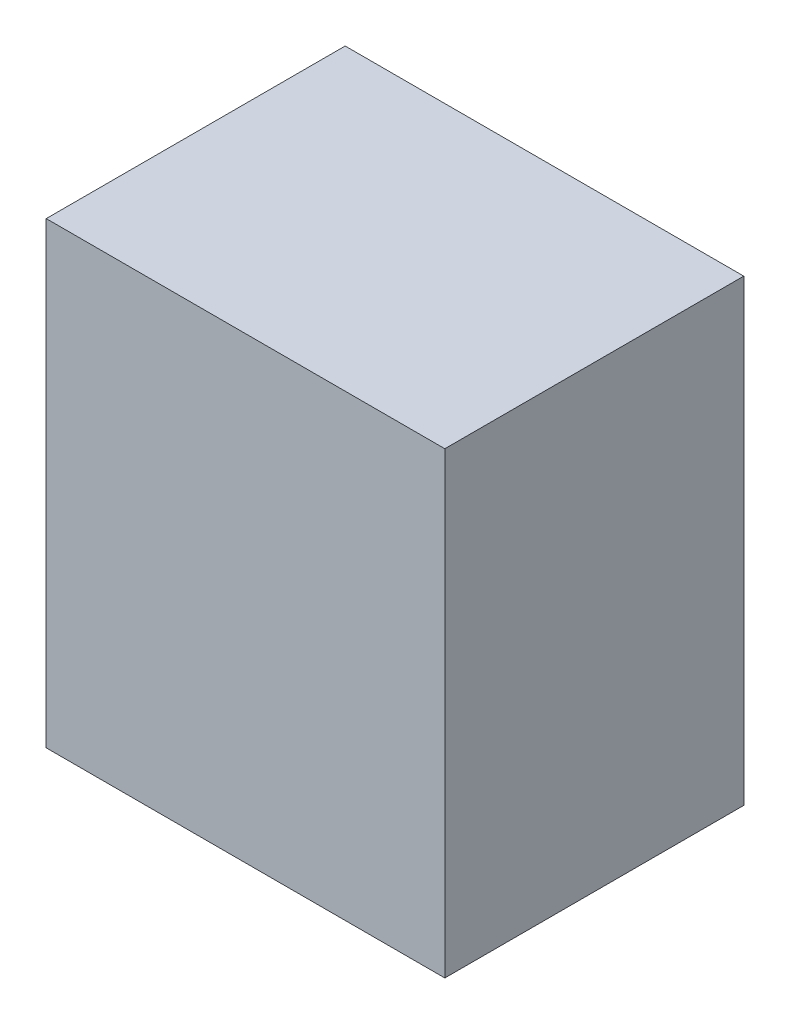
from build123d import *

# Parameters (mm, degrees)
SKETCH2_W           = 20
SKETCH2_H           = 15
BOSS_EXTRUDE1_DEPTH = 23


with BuildPart() as part:
    # Sketch2 → Boss-Extrude1 (new body)
    with BuildSketch(Plane(origin=(0, 0, 0), x_dir=(1, 0, 0), z_dir=(0, 1, 0))):
        Rectangle(SKETCH2_W, SKETCH2_H)
    extrude(amount=BOSS_EXTRUDE1_DEPTH)


solid = part.part
